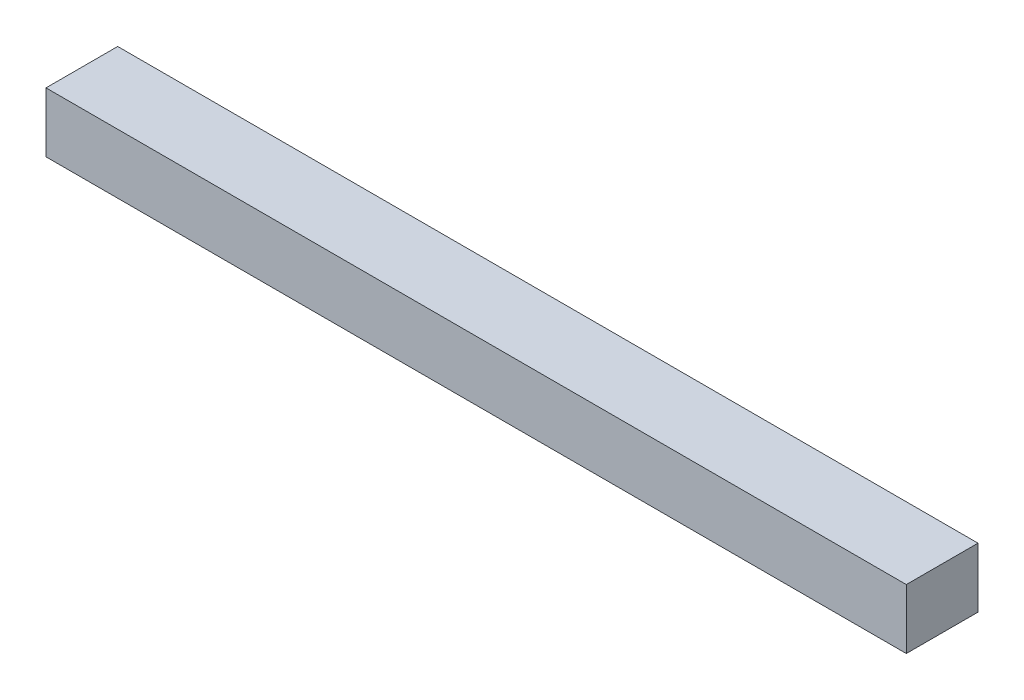
from build123d import *

# Parameters (mm, degrees)
SKETCH_2_W      = 30
SKETCH_2_H      = 25
EXTRUDE_1_DEPTH = 360


with BuildPart() as part:
    # Эскиз2 → Бобышка-Вытянуть1 (new body)
    with BuildSketch(Plane(origin=(0, 0, 0), x_dir=(0, 0, -1), z_dir=(1, 0, 0))):
        Rectangle(SKETCH_2_W, SKETCH_2_H)
    extrude(amount=EXTRUDE_1_DEPTH)


solid = part.part
